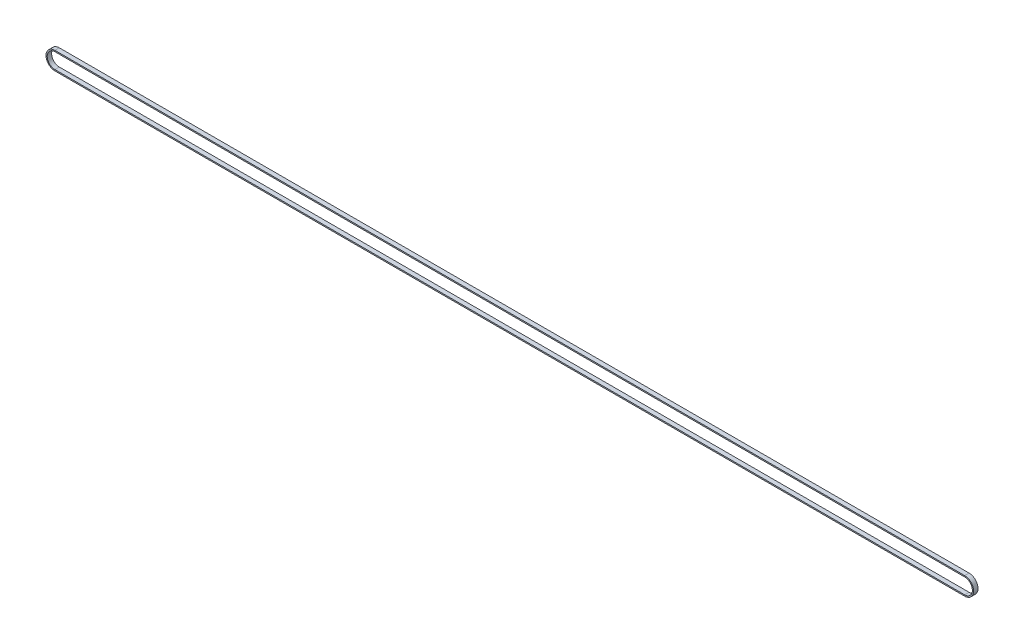
from build123d import *

# Parameters (mm, degrees)
EXTRUDE_THIN1_DEPTH = 2.5


with BuildPart() as part:
    # Sketch1 → Extrude-Thin1 (new body, symmetric)
    with BuildSketch(Plane.XY):
        with BuildLine():
            Line((1032, -10.13), (0, -10.13))
            ThreePointArc((0, -10.13), (-10.13, 0), (0, 10.13))
            Line((0, 10.13), (1032, 10.13))
            ThreePointArc((1032, 10.13), (1042.13, 0), (1032, -10.13))
        make_face()
        with BuildLine():
            Line((1032, -8.75), (0, -8.75))
            ThreePointArc((0, -8.75), (-8.75, 0), (0, 8.75))
            Line((0, 8.75), (1032, 8.75))
            ThreePointArc((1032, 8.75), (1040.75, 0), (1032, -8.75))
        make_face(mode=Mode.SUBTRACT)
    extrude(amount=EXTRUDE_THIN1_DEPTH, both=True)


solid = part.part
